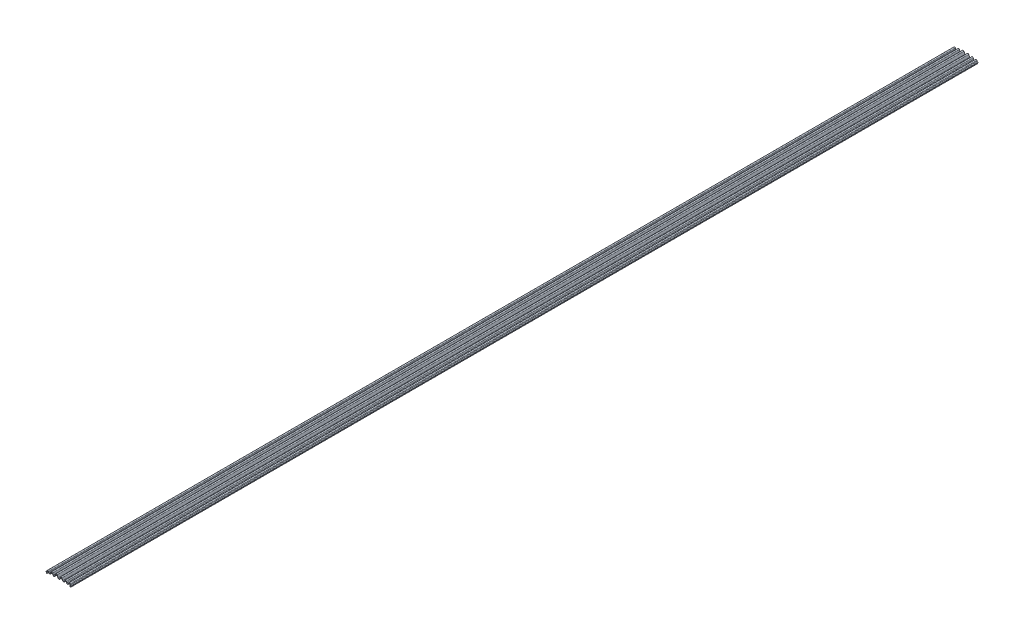
from build123d import *

# Parameters (mm, degrees)
BOSS_EXTRUDE1_DEPTH = 1828.8


with BuildPart() as part:
    # Sketch1 → Boss-Extrude1 (new body, symmetric)
    with BuildSketch(Plane.XY):
        with BuildLine():
            Line((-50.78476, 0.5715), (-50.559736774, -0.046746233))
            ThreePointArc((-50.559736774, -0.046746233), (-50.373749752, -0.289129238), (-50.082372922, -0.381))
            Line((-50.082372922, -0.381), (-47.99076, -0.381))
            ThreePointArc((-47.99076, -0.381), (-46.78426, -1.5875), (-47.99076, -2.794))
            Line((-47.99076, -2.794), (-49.015693786, -2.794))
            ThreePointArc((-49.015693786, -2.794), (-49.327790715, -2.956467378), (-49.373716675, -3.305309675))
            Line((-49.373716675, -3.305309675), (-49.14727152, -3.927462624))
            ThreePointArc((-49.14727152, -3.927462624), (-49.058345853, -4.066870737), (-48.918733274, -4.155475049))
            ThreePointArc((-48.918733274, -4.155475049), (-45.435630481, -2.550278994), (-46.993353033, 0.954312265))
            ThreePointArc((-46.993353033, 0.954312265), (-47.222592561, 1.211859281), (-47.15011647, 1.548947463))
            ThreePointArc((-47.15011647, 1.548947463), (-46.815832499, 2.017112771), (-46.541259709, 2.522616788))
            Line((-46.541259709, 2.522616788), (-45.135349464, 5.537601038))
            ThreePointArc((-45.135349464, 5.537601038), (-43.39673428, 6.645221066), (-41.658119097, 5.537601038))
            Line((-41.658119097, 5.537601038), (-40.252208852, 2.522616788))
            ThreePointArc((-40.252208852, 2.522616788), (-35.993468561, -0.1905), (-31.734728269, 2.522616788))
            Line((-31.734728269, 2.522616788), (-29.160039084, 8.044055564))
            ThreePointArc((-29.160039084, 8.044055564), (-27.4214239, 9.151675593), (-25.682808717, 8.044055564))
            Line((-25.682808717, 8.044055564), (-23.108119532, 2.522616788))
            ThreePointArc((-23.108119532, 2.522616788), (-18.84937924, -0.1905), (-14.590638949, 2.522616788))
            Line((-14.590638949, 2.522616788), (-10.61576511, 11.046761243))
            ThreePointArc((-10.61576511, 11.046761243), (-8.877149927, 12.154381272), (-7.138534743, 11.046761243))
            Line((-7.138534743, 11.046761243), (-3.163660904, 2.522616788))
            ThreePointArc((-3.163660904, 2.522616788), (1.095079387, -0.1905), (5.353819678, 2.522616788))
            Line((5.353819678, 2.522616788), (8.810059444, 9.934546884))
            ThreePointArc((8.810059444, 9.934546884), (10.548674627, 11.042166912), (12.287289811, 9.934546884))
            Line((12.287289811, 9.934546884), (15.743529576, 2.522616788))
            ThreePointArc((15.743529576, 2.522616788), (20.002269867, -0.1905), (24.261010159, 2.522616788))
            Line((24.261010159, 2.522616788), (26.3256628, 6.950278665))
            ThreePointArc((26.3256628, 6.950278665), (28.064277983, 8.057898694), (29.802893167, 6.950278665))
            Line((29.802893167, 6.950278665), (31.867545808, 2.522616788))
            ThreePointArc((31.867545808, 2.522616788), (36.126286099, -0.1905), (40.385026391, 2.522616788))
            Line((40.385026391, 2.522616788), (41.668563615, 5.275171249))
            ThreePointArc((41.668563615, 5.275171249), (43.407178799, 6.382791278), (45.145793982, 5.275171249))
            Line((45.145793982, 5.275171249), (46.382028178, 2.624058461))
            ThreePointArc((46.382028178, 2.624058461), (46.695888569, 2.053812951), (47.082925376, 1.530467179))
            ThreePointArc((47.082925376, 1.530467179), (47.162849135, 1.194920043), (46.939140922, 0.932366577))
            ThreePointArc((46.939140922, 0.932366577), (45.446088081, -2.577588419), (48.918733274, -4.155475049))
            ThreePointArc((48.918733274, -4.155475049), (49.058345853, -4.066870737), (49.14727152, -3.927462624))
            Line((49.14727152, -3.927462624), (49.373716675, -3.305309675))
            ThreePointArc((49.373716675, -3.305309675), (49.327790715, -2.956467378), (49.015693786, -2.794))
            Line((49.015693786, -2.794), (47.99076, -2.794))
            ThreePointArc((47.99076, -2.794), (46.78426, -1.5875), (47.99076, -0.381))
            Line((47.99076, -0.381), (50.097612922, -0.381))
            ThreePointArc((50.097612922, -0.381), (50.388989752, -0.289129238), (50.574976774, -0.046746233))
            Line((50.574976774, -0.046746233), (50.8, 0.5715))
            Line((50.8, 0.5715), (50.8, 1.3335))
            ThreePointArc((50.8, 1.3335), (48.999674203, 1.858247117), (47.763241246, 3.268128692))
            Line((47.763241246, 3.268128692), (46.52700705, 5.91924148))
            ThreePointArc((46.52700705, 5.91924148), (43.407178799, 7.906791278), (40.287350548, 5.91924148))
            Line((40.287350548, 5.91924148), (39.003813323, 3.166687019))
            ThreePointArc((39.003813323, 3.166687019), (36.126286099, 1.3335), (33.248758876, 3.166687019))
            Line((33.248758876, 3.166687019), (31.184106234, 7.594348896))
            ThreePointArc((31.184106234, 7.594348896), (28.064277983, 9.581898694), (24.944449732, 7.594348896))
            Line((24.944449732, 7.594348896), (22.879797091, 3.166687019))
            ThreePointArc((22.879797091, 3.166687019), (20.002269867, 1.3335), (17.124742644, 3.166687019))
            Line((17.124742644, 3.166687019), (13.668502878, 10.578617115))
            ThreePointArc((13.668502878, 10.578617115), (10.548674627, 12.566166912), (7.428846376, 10.578617115))
            Line((7.428846376, 10.578617115), (3.972606611, 3.166687019))
            ThreePointArc((3.972606611, 3.166687019), (1.095079387, 1.3335), (-1.782447837, 3.166687019))
            Line((-1.782447837, 3.166687019), (-5.757321676, 11.690831474))
            ThreePointArc((-5.757321676, 11.690831474), (-8.877149927, 13.678381272), (-11.996978178, 11.690831474))
            Line((-11.996978178, 11.690831474), (-15.971852016, 3.166687019))
            ThreePointArc((-15.971852016, 3.166687019), (-18.84937924, 1.3335), (-21.726906464, 3.166687019))
            Line((-21.726906464, 3.166687019), (-24.30159565, 8.688125795))
            ThreePointArc((-24.30159565, 8.688125795), (-27.4214239, 10.675675593), (-30.541252151, 8.688125795))
            Line((-30.541252151, 8.688125795), (-33.115941337, 3.166687019))
            ThreePointArc((-33.115941337, 3.166687019), (-35.993468561, 1.3335), (-38.870995784, 3.166687019))
            Line((-38.870995784, 3.166687019), (-40.276906029, 6.181671269))
            ThreePointArc((-40.276906029, 6.181671269), (-43.403924246, 8.169213557), (-46.522612518, 6.168625961))
            Line((-46.522612518, 6.168625961), (-47.901652661, 3.178719165))
            ThreePointArc((-47.901652661, 3.178719165), (-49.073244466, 1.834301134), (-50.78476, 1.3335))
            Line((-50.78476, 1.3335), (-50.78476, 0.5715))
        make_face()
    extrude(amount=BOSS_EXTRUDE1_DEPTH, both=True)


solid = part.part
